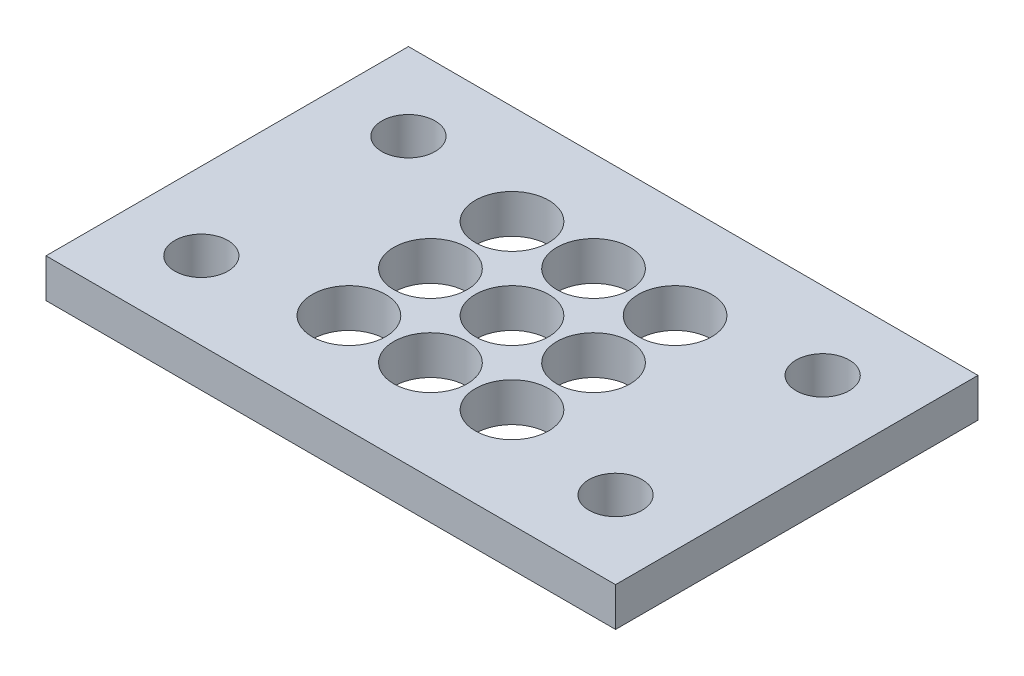
from build123d import *

# Parameters (mm, degrees)
SKETCH1_W           = 69.85
SKETCH1_H           = 44.45
SKETCH1_R           = 4.5
SKETCH1_R_2         = 3.2639
BOSS_EXTRUDE1_DEPTH = 4.7625


with BuildPart() as part:
    # Sketch1 → Boss-Extrude1 (new body)
    with BuildSketch(Plane(origin=(0, 0, 0), x_dir=(1, 0, 0), z_dir=(0, 1, 0))):
        with Locations((34.925, 22.225)):
            Rectangle(SKETCH1_W, SKETCH1_H)
        with Locations((44.925, 12.225)):
            Circle(SKETCH1_R, mode=Mode.SUBTRACT)
        with Locations((34.925, 12.225)):
            Circle(SKETCH1_R, mode=Mode.SUBTRACT)
        with Locations((24.925, 12.225)):
            Circle(SKETCH1_R, mode=Mode.SUBTRACT)
        with Locations((24.925, 32.225)):
            Circle(SKETCH1_R, mode=Mode.SUBTRACT)
        with Locations((24.925, 22.225)):
            Circle(SKETCH1_R, mode=Mode.SUBTRACT)
        with Locations((34.925, 32.225)):
            Circle(SKETCH1_R, mode=Mode.SUBTRACT)
        with Locations((44.925, 32.225)):
            Circle(SKETCH1_R, mode=Mode.SUBTRACT)
        with Locations((44.925, 22.225)):
            Circle(SKETCH1_R, mode=Mode.SUBTRACT)
        with Locations((34.925, 22.225)):
            Circle(SKETCH1_R, mode=Mode.SUBTRACT)
        with Locations((60.325, 9.525)):
            Circle(SKETCH1_R_2, mode=Mode.SUBTRACT)
        with Locations((9.525, 9.525)):
            Circle(SKETCH1_R_2, mode=Mode.SUBTRACT)
        with Locations((60.325, 34.925)):
            Circle(SKETCH1_R_2, mode=Mode.SUBTRACT)
        with Locations((9.525, 34.925)):
            Circle(SKETCH1_R_2, mode=Mode.SUBTRACT)
    extrude(amount=BOSS_EXTRUDE1_DEPTH)


solid = part.part
